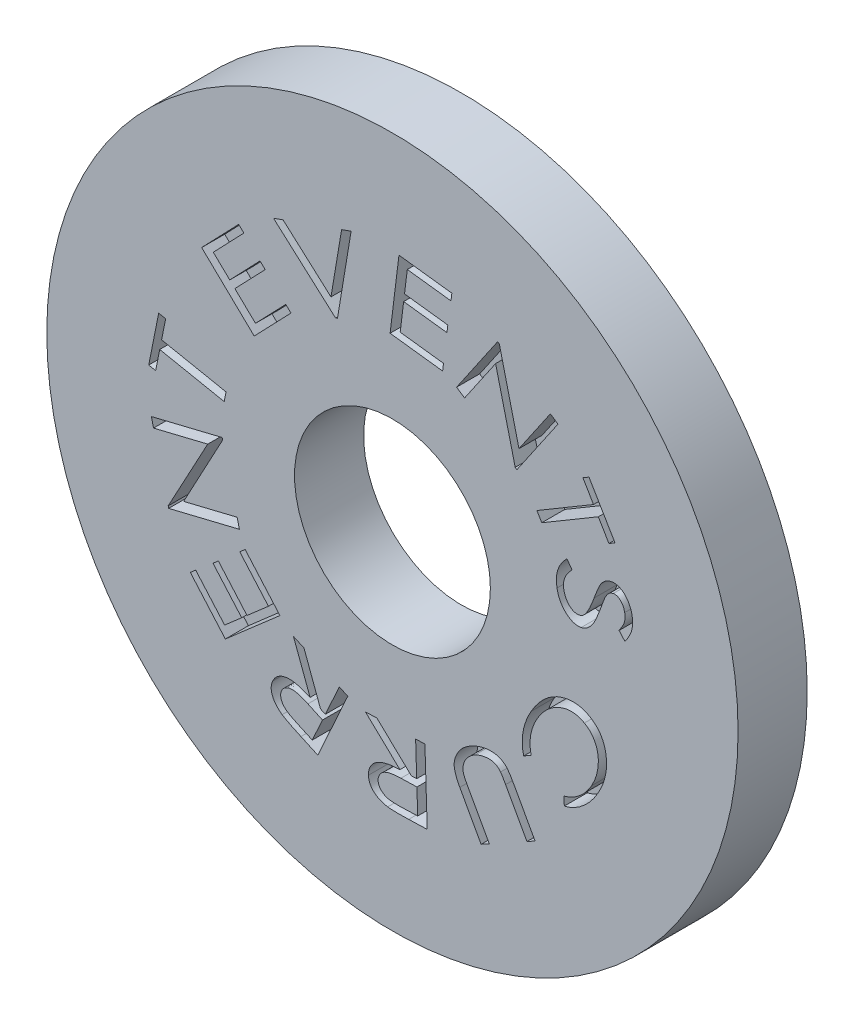
from build123d import *

# Parameters (mm, degrees)
SKETCH1_R           = 15
BOSS_EXTRUDE1_DEPTH = 3
SKETCH3_R           = 4.25
CUT_EXTRUDE1_DEPTH  = 4
CUT_EXTRUDE3_DEPTH  = 1


with BuildPart() as part:
    # Sketch1 → Boss-Extrude1 (new body)
    with BuildSketch(Plane.XY):
        Circle(SKETCH1_R)
    extrude(amount=BOSS_EXTRUDE1_DEPTH)

    # Sketch3 → Cut-Extrude1 (cut, through all)
    with BuildSketch(Plane.XY.offset(3)):
        Circle(SKETCH3_R)
    extrude(amount=-CUT_EXTRUDE1_DEPTH, mode=Mode.SUBTRACT)

    # Sketch7 → Cut-Extrude3 (cut)
    with BuildSketch(Plane.XY.offset(3)):
        with BuildLine():
            Line((7.572567921, 2.778173454), (7.793266038, 2.472884993))
            add(Edge.make_bspline(
                [(7.793266038, 2.472884993), (7.758243177, 2.435741938), (7.690623687, 2.364028938), (7.603508013, 2.250334888), (7.533286277, 2.135948941), (7.480151232, 2.020806722), (7.442138205, 1.905496622), (7.422287905, 1.789167337), (7.419200953, 1.672269445), (7.430271316, 1.595517723), (7.435824131, 1.557019608)],
                knots=[0, 0, 0, 0, 0.000153078, 0.000295552, 0.000428846, 0.000554914, 0.000675193, 0.000791989, 0.000907772, 0.001024295, 0.001024295, 0.001024295, 0.001024295], degree=3))
            add(Edge.make_bspline(
                [(7.435824131, 1.557019608), (7.442771562, 1.524610872), (7.456540718, 1.460379804), (7.4890804, 1.367902537), (7.529040709, 1.279839065), (7.576884374, 1.197526866), (7.63169335, 1.12390142), (7.690723663, 1.059825704), (7.755198845, 1.008566954), (7.822411558, 0.968045646), (7.892127768, 0.940052812), (7.961924082, 0.923007684), (8.031981335, 0.917975072), (8.077612177, 0.924229934), (8.100462552, 0.927362156)],
                knots=[0, 0, 0, 0, 9.9349e-05, 0.000196901, 0.000293385, 0.00038916, 0.000481892, 0.000568283, 0.000649733, 0.000728159, 0.00080292, 0.000874191, 0.000943025, 0.00101207, 0.00101207, 0.00101207, 0.00101207], degree=3))
            add(Edge.make_bspline(
                [(8.100462552, 0.927362156), (8.126084368, 0.933936214), (8.17844969, 0.947372132), (8.251872782, 0.988690006), (8.320684938, 1.046336853), (8.360264918, 1.093933283), (8.380946327, 1.118803462)],
                knots=[0, 0, 0, 0, 7.9074e-05, 0.000161609, 0.000250128, 0.000346997, 0.000346997, 0.000346997, 0.000346997], degree=3))
            add(Edge.make_bspline(
                [(8.380946327, 1.118803462), (8.39565008, 1.138962849), (8.426795504, 1.181664371), (8.470095641, 1.253575895), (8.515376991, 1.334878874), (8.560775252, 1.42654351), (8.607348756, 1.527873565), (8.654087191, 1.639448498), (8.702651197, 1.760788775), (8.733736506, 1.84568595), (8.749836551, 1.889656828)],
                knots=[0, 0, 0, 0, 7.4823e-05, 0.000158491, 0.000251586, 0.000353983, 0.000465259, 0.000586104, 0.000716847, 0.000857316, 0.000857316, 0.000857316, 0.000857316], degree=3))
            add(Edge.make_bspline(
                [(8.749836551, 1.889656828), (8.765811525, 1.933380955), (8.796297421, 2.01682204), (8.841979614, 2.135190747), (8.885448883, 2.240821815), (8.925013743, 2.334131591), (8.962128693, 2.414635037), (8.995504728, 2.482778827), (9.02603426, 2.538680429), (9.047896664, 2.570130158), (9.057669083, 2.584188078)],
                knots=[0, 0, 0, 0, 0.000139652, 0.000266505, 0.000380599, 0.000482318, 0.000570539, 0.000646484, 0.00070999, 0.000761323, 0.000761323, 0.000761323, 0.000761323], degree=3))
            add(Edge.make_bspline(
                [(9.057669083, 2.584188078), (9.072799978, 2.604399424), (9.102238214, 2.643722041), (9.151301418, 2.696828372), (9.201768533, 2.744088522), (9.255245124, 2.784479147), (9.310635476, 2.819101675), (9.368720334, 2.84737176), (9.429502978, 2.868385265), (9.471191145, 2.877776895), (9.492069123, 2.882480345)],
                knots=[0, 0, 0, 0, 7.5697e-05, 0.000147273, 0.000216585, 0.000282859, 0.000347985, 0.000412273, 0.000476236, 0.000540408, 0.000540408, 0.000540408, 0.000540408], degree=3))
            add(Edge.make_bspline(
                [(9.492069123, 2.882480345), (9.525487591, 2.887480101), (9.591522657, 2.897359645), (9.691872493, 2.891386261), (9.790280553, 2.869652966), (9.885796731, 2.830726385), (9.977833579, 2.777774496), (10.064054371, 2.709986522), (10.142852329, 2.626974709), (10.214626778, 2.531523883), (10.277647402, 2.425473252), (10.330077135, 2.311166633), (10.371940156, 2.189956218), (10.390336334, 2.105491425), (10.399666278, 2.062653623)],
                knots=[0, 0, 0, 0, 0.000101141, 0.000199855, 0.000299539, 0.000402291, 0.000508002, 0.000617169, 0.000730075, 0.00085041, 0.000974757, 0.001099404, 0.001227123, 0.001358557, 0.001358557, 0.001358557, 0.001358557], degree=3))
            add(Edge.make_bspline(
                [(10.399666278, 2.062653623), (10.406968125, 2.016545914), (10.421409034, 1.925358391), (10.426457156, 1.787710684), (10.415815967, 1.652205938), (10.396123285, 1.540457631), (10.371326108, 1.451471841), (10.3480234, 1.382372), (10.317425083, 1.312204002), (10.283312702, 1.238982201), (10.242466813, 1.164523065), (10.19630228, 1.087807297), (10.145158452, 1.009012467), (10.107344602, 0.957083536), (10.088017641, 0.930542244)],
                knots=[0, 0, 0, 0, 0.000139959, 0.000276797, 0.000412016, 0.000547123, 0.000616405, 0.000689014, 0.00076568, 0.000845909, 0.000931287, 0.001020294, 0.001114495, 0.001212977, 0.001212977, 0.001212977, 0.001212977], degree=3))
            Line((10.088017641, 0.930542244), (9.835518642, 1.21611416))
            add(Edge.make_bspline(
                [(9.835518642, 1.21611416), (9.850666738, 1.237884108), (9.879987813, 1.280022627), (9.920896489, 1.342137684), (9.956297727, 1.401704472), (9.988677296, 1.45737921), (10.015174277, 1.510900621), (10.037632888, 1.561125257), (10.055616413, 1.608227845), (10.073535384, 1.666851191), (10.087692838, 1.739748458), (10.095416924, 1.828210864), (10.093172952, 1.918782094), (10.08342497, 1.978777462), (10.078477376, 2.009228142)],
                knots=[0, 0, 0, 0, 7.9566e-05, 0.00015401, 0.000223055, 0.000287428, 0.00034716, 0.000402115, 0.000452437, 0.00049831, 0.000585873, 0.000674608, 0.000764322, 0.000856788, 0.000856788, 0.000856788, 0.000856788], degree=3))
            add(Edge.make_bspline(
                [(10.078477376, 2.009228142), (10.070009004, 2.047054558), (10.05372202, 2.11980505), (10.012851345, 2.220461733), (9.95867451, 2.306810013), (9.904349115, 2.36830856), (9.855554319, 2.40776404), (9.819470182, 2.434039548), (9.781592753, 2.453695577), (9.742935279, 2.468427785), (9.703756584, 2.478999274), (9.663496358, 2.48299816), (9.622638128, 2.483669132), (9.595490886, 2.47904305), (9.581747609, 2.476701099)],
                knots=[0, 0, 0, 0, 0.000116156, 0.0002234, 0.000323988, 0.000420807, 0.000467795, 0.000512083, 0.000554473, 0.000595342, 0.000636067, 0.00067575, 0.000716455, 0.000758191, 0.000758191, 0.000758191, 0.000758191], degree=3))
            add(Edge.make_bspline(
                [(9.581747609, 2.476701099), (9.565072377, 2.47292768), (9.53186137, 2.465412399), (9.483996766, 2.445591538), (9.438315171, 2.419487886), (9.393899829, 2.386365896), (9.351219073, 2.343576112), (9.308479524, 2.290504101), (9.267096025, 2.225041266), (9.24077765, 2.177078396), (9.226849772, 2.151696091)],
                knots=[0, 0, 0, 0, 5.1214e-05, 0.000102, 0.000154698, 0.000208759, 0.000267676, 0.000335518, 0.000412789, 0.000499646, 0.000499646, 0.000499646, 0.000499646], degree=3))
            add(Edge.make_bspline(
                [(9.226849772, 2.151696091), (9.222304384, 2.142196966), (9.211520681, 2.119660775), (9.195330118, 2.078817495), (9.174236103, 2.026370818), (9.149622593, 1.961414805), (9.120814592, 1.884312109), (9.08891472, 1.794783878), (9.051377586, 1.69361897), (9.026367472, 1.621730509), (9.013147849, 1.583732349)],
                knots=[0, 0, 0, 0, 3.1584e-05, 7.4931e-05, 0.00013174, 0.000201194, 0.000283302, 0.000378667, 0.000486312, 0.000607004, 0.000607004, 0.000607004, 0.000607004], degree=3))
            add(Edge.make_bspline(
                [(9.013147849, 1.583732349), (8.99693264, 1.537819533), (8.965599781, 1.449101604), (8.915081722, 1.322733423), (8.865446754, 1.206737233), (8.816841092, 1.100698278), (8.767229789, 1.005267137), (8.717832275, 0.920121637), (8.669136796, 0.845158972), (8.619566465, 0.780705237), (8.569276918, 0.724678569), (8.518337233, 0.6751533), (8.466904572, 0.630514961), (8.413224126, 0.593300395), (8.358839302, 0.560863449), (8.303010082, 0.534913767), (8.245924331, 0.514706891), (8.206996406, 0.506137069), (8.187596968, 0.501866363)],
                knots=[0, 0, 0, 0, 0.000146063, 0.000282239, 0.000408177, 0.000524561, 0.000632091, 0.000730705, 0.000819788, 0.00090006, 0.000974376, 0.001045439, 0.001113115, 0.001178402, 0.001241123, 0.001302869, 0.00136281, 0.001422355, 0.001422355, 0.001422355, 0.001422355], degree=3))
            add(Edge.make_bspline(
                [(8.187596968, 0.501866363), (8.15968128, 0.49741788), (8.104497268, 0.488624072), (8.020600014, 0.49028), (7.937808787, 0.50050963), (7.856040827, 0.523114416), (7.774748109, 0.55460006), (7.695152612, 0.598866223), (7.615816175, 0.652521274), (7.538602844, 0.716463895), (7.464506472, 0.787964483), (7.397782196, 0.867585622), (7.337029209, 0.952218288), (7.28351866, 1.042939592), (7.236984005, 1.139329352), (7.197507725, 1.241642056), (7.164835804, 1.349861065), (7.149262538, 1.424802589), (7.141347969, 1.462888999)],
                knots=[0, 0, 0, 0, 8.4648e-05, 0.000167332, 0.000250719, 0.000334337, 0.000421146, 0.000511651, 0.000606909, 0.000708134, 0.000812031, 0.000915374, 0.001019327, 0.00112426, 0.001230933, 0.001340069, 0.001452953, 0.001569608, 0.001569608, 0.001569608, 0.001569608], degree=3))
            add(Edge.make_bspline(
                [(7.141347969, 1.462888999), (7.136412961, 1.492528006), (7.126609492, 1.551406347), (7.116823072, 1.639489922), (7.113449983, 1.72658096), (7.113435033, 1.812193112), (7.120454573, 1.896647888), (7.130617689, 1.980058926), (7.147775334, 2.06206888), (7.168297821, 2.143515958), (7.196069086, 2.223982449), (7.229804578, 2.304094831), (7.269936956, 2.384274193), (7.318219776, 2.463251223), (7.371298936, 2.543242757), (7.432336273, 2.621889806), (7.498983797, 2.701221181), (7.547682473, 2.75214893), (7.572567921, 2.778173454)],
                knots=[0, 0, 0, 0, 9.0135e-05, 0.000179055, 0.000265637, 0.000351502, 0.000435697, 0.000519714, 0.00060341, 0.000686867, 0.000771543, 0.000858482, 0.000947511, 0.001040226, 0.001136011, 0.001235363, 0.001338705, 0.001446701, 0.001446701, 0.001446701, 0.001446701], degree=3))
        make_face()
        Polygon((8.266054911, 6.171653301), (8.530002227, 6.32747762), (9.658297499, 4.418788718), (9.394350183, 4.262964399), (8.935781473, 5.038905905), (6.480753428, 3.58687766), (6.270867611, 3.941775496), (8.725895656, 5.393803742), align=None)
        Polygon((2.785093321, 6.834011202), (4.566578698, 9.435959319), (4.639084708, 9.386349944), (5.491348329, 5.877440689), (6.854970124, 7.868811883), (7.183791238, 7.643661643), (5.402305861, 5.041713526), (5.327255781, 5.092594936), (4.476900212, 8.565251186), (3.129814876, 6.598048662), align=None)
        Polygon((0.282816593, 10.544771408), (2.578204213, 10.263015599), (2.540043155, 9.954547049), (0.644710623, 10.187329501), (0.525139309, 9.209134389), (2.403935383, 8.97825999), (2.365774325, 8.671699493), (0.486978251, 8.902573892), (0.336878091, 7.675695888), (2.215674165, 7.444821488), (2.177513107, 7.136352939), (-0.101338055, 7.416200695), align=None)
        Polygon((-5.160182932, 9.208626909), (-4.746771474, 9.355546982), (-2.667629847, 7.499011525), (-2.206517067, 10.259964049), (-1.793105608, 10.407520139), (-2.38523802, 6.836281156), (-2.467920312, 6.807024345), align=None)
        Polygon((-8.278789316, 6.549158581), (-6.672208787, 8.224429014), (-6.447058546, 8.008819038), (-7.773791319, 6.625480697), (-7.060815558, 5.941761746), (-5.745531103, 7.313015753), (-5.522288915, 7.098677812), (-6.83757337, 5.727423806), (-5.942696567, 4.869436025), (-4.627412112, 6.240690032), (-4.402897889, 6.025716073), (-5.998030101, 4.362529975), align=None)
        Polygon((-10.274879437, 0.92545457), (-10.576351793, 0.985240227), (-10.143859806, 3.150880251), (-9.84238745, 3.091094594), (-10.017928315, 2.210846197), (-7.220086769, 1.651786701), (-7.300861008, 1.249187543), (-10.098702554, 1.808247038), align=None)
        Polygon((-6.640662188, -3.220738253), (-9.710719279, -3.968694983), (-9.731071843, -3.883468621), (-8.016368318, -0.706560568), (-10.366453454, -1.278976434), (-10.460584063, -0.892913733), (-7.390526971, -0.144957003), (-7.368902372, -0.232727435), (-9.060073245, -3.381650712), (-6.73924492, -2.816231041), align=None)
        Polygon((-7.250871739, -7.6486715), (-8.770953871, -5.905983198), (-8.537535401, -5.702457557), (-7.282672621, -7.141129432), (-6.542348102, -6.49557154), (-7.786398582, -5.069620017), (-7.554888166, -4.867366411), (-6.310837685, -6.293317934), (-5.38161593, -5.483031476), (-6.625666411, -4.057079953), (-6.392247941, -3.853554312), (-4.88297811, -5.583522261), align=None)
        with BuildLine():
            Line((-3.237172262, -10.007422843), (-3.971136605, -9.674149605))
            add(Edge.make_bspline(
                [(-3.971136605, -9.674149605), (-4.020146303, -9.651756109), (-4.114099173, -9.608827192), (-4.248184689, -9.546048156), (-4.36920391, -9.487437973), (-4.477404668, -9.433501841), (-4.572817622, -9.383884078), (-4.655702968, -9.339192121), (-4.725065818, -9.29785805), (-4.766439641, -9.271023318), (-4.785239169, -9.258830094)],
                knots=[0, 0, 0, 0, 0.00016165, 0.000309887, 0.000444152, 0.000565037, 0.000672567, 0.000766777, 0.000847494, 0.000914713, 0.000914713, 0.000914713, 0.000914713], degree=3))
            add(Edge.make_bspline(
                [(-4.785239169, -9.258830094), (-4.809619315, -9.241301048), (-4.857476529, -9.206892259), (-4.924499844, -9.151341698), (-4.985759161, -9.093401721), (-5.041340121, -9.032899487), (-5.091024307, -8.969569706), (-5.135718183, -8.904396585), (-5.174014995, -8.836428788), (-5.206610336, -8.766842665), (-5.231839513, -8.695637943), (-5.250778671, -8.624481215), (-5.260979519, -8.553176931), (-5.263308176, -8.482219), (-5.259273124, -8.411137756), (-5.246012609, -8.340247027), (-5.225999546, -8.26932921), (-5.206576606, -8.223633142), (-5.196742574, -8.200496761)],
                knots=[0, 0, 0, 0, 9.0063e-05, 0.000176791, 0.000260921, 0.000342851, 0.000423012, 0.000502218, 0.000579687, 0.000656803, 0.000732444, 0.000806027, 0.000877354, 0.000947998, 0.001018736, 0.001090471, 0.001163944, 0.001239296, 0.001239296, 0.001239296, 0.001239296], degree=3))
            add(Edge.make_bspline(
                [(-5.196742574, -8.200496761), (-5.187486087, -8.181478543), (-5.16923604, -8.143982313), (-5.137237263, -8.090920657), (-5.101552439, -8.041711157), (-5.061993645, -7.996542661), (-5.01898891, -7.954907952), (-4.972766314, -7.916518493), (-4.922170125, -7.882979442), (-4.868593029, -7.853000283), (-4.811921368, -7.826759221), (-4.752247377, -7.805389603), (-4.690198955, -7.788079247), (-4.625562416, -7.775271329), (-4.558354949, -7.767435134), (-4.488507454, -7.762515184), (-4.416263048, -7.763595048), (-4.341055421, -7.768540713), (-4.262133849, -7.779236592), (-4.178310125, -7.794069234), (-4.089853576, -7.816451239), (-3.996189527, -7.842997447), (-3.89758418, -7.875633483), (-3.794217172, -7.913961151), (-3.685420602, -7.95716586), (-3.612100137, -7.989714164), (-3.574261605, -8.006511384)],
                knots=[0, 0, 0, 0, 6.343e-05, 0.000125058, 0.000185613, 0.000245565, 0.000304936, 0.000365035, 0.000425541, 0.000486761, 0.000549084, 0.00061266, 0.000676699, 0.000742184, 0.000810107, 0.000879576, 0.000952085, 0.001026673, 0.001105562, 0.001190893, 0.001281905, 0.001379141, 0.001482923, 0.001593395, 0.001709847, 0.001834033, 0.001834033, 0.001834033, 0.001834033], degree=3))
            Line((-3.574261605, -8.006511384), (-4.294869577, -6.073017795))
            Line((-4.294869577, -6.073017795), (-3.838844938, -6.279723524))
            Line((-3.838844938, -6.279723524), (-3.120781036, -8.211945078))
            Line((-3.120781036, -8.211945078), (-2.910259201, -8.307347722))
            Line((-2.910259201, -8.307347722), (-2.306042454, -6.974890791))
            Line((-2.306042454, -6.974890791), (-1.937788247, -7.142163428))
            Line((-1.937788247, -7.142163428), (-3.237172262, -10.007422843))
        make_face()
        with BuildLine():
            Line((-3.478222943, -9.559666432), (-3.036826709, -8.585923444))
            Line((-3.036826709, -8.585923444), (-3.668392214, -8.29462737))
            add(Edge.make_bspline(
                [(-3.668392214, -8.29462737), (-3.698236127, -8.281371688), (-3.755786989, -8.255809492), (-3.839890685, -8.2206021), (-3.918923424, -8.190237326), (-3.992430387, -8.163084189), (-4.061262269, -8.14143662), (-4.124990725, -8.124393506), (-4.183168223, -8.110437329), (-4.252752908, -8.099953278), (-4.333631815, -8.093080903), (-4.42610868, -8.099771178), (-4.512959553, -8.117727357), (-4.592613945, -8.149241155), (-4.664333348, -8.190833051), (-4.725383988, -8.243356856), (-4.777222122, -8.303992993), (-4.801179872, -8.351089281), (-4.813223944, -8.374765591)],
                knots=[0, 0, 0, 0, 9.7965e-05, 0.000188916, 0.000273485, 0.00035195, 0.000423963, 0.000489842, 0.000549861, 0.000603294, 0.000700856, 0.000792663, 0.000880484, 0.000965876, 0.001048559, 0.001127962, 0.001206545, 0.001285989, 0.001285989, 0.001285989, 0.001285989], degree=3))
            add(Edge.make_bspline(
                [(-4.813223944, -8.374765591), (-4.822696139, -8.398864772), (-4.84153128, -8.446785183), (-4.852162702, -8.523882148), (-4.850569538, -8.603069594), (-4.833330968, -8.683269469), (-4.80429523, -8.762326425), (-4.763225082, -8.837826274), (-4.709305298, -8.907176674), (-4.65634421, -8.962074624), (-4.605150991, -9.003570219), (-4.558846766, -9.036876631), (-4.504997641, -9.071439066), (-4.443861007, -9.107637425), (-4.375316107, -9.145325843), (-4.299329892, -9.184427478), (-4.215860386, -9.225315956), (-4.157346384, -9.251980028), (-4.126960924, -9.265826288)],
                knots=[0, 0, 0, 0, 7.744e-05, 0.000153987, 0.000231605, 0.000314054, 0.000398769, 0.000483589, 0.000570725, 0.000661576, 0.000711741, 0.000768228, 0.00083262, 0.000903629, 0.000981343, 0.00106725, 0.00115998, 0.001260151, 0.001260151, 0.001260151, 0.001260151], degree=3))
            Line((-4.126960924, -9.265826288), (-3.478222943, -9.559666432))
        make_face(mode=Mode.SUBTRACT)
        with BuildLine():
            Line((1.509342292, -10.423242667), (0.70541601, -10.448683372))
            add(Edge.make_bspline(
                [(0.70541601, -10.448683372), (0.651569566, -10.450311331), (0.548551903, -10.4534259), (0.400770495, -10.455626111), (0.266563096, -10.457556859), (0.145711011, -10.455859051), (0.038400825, -10.453762096), (-0.055331815, -10.449303709), (-0.1355883, -10.443512412), (-0.184394549, -10.437015366), (-0.206633269, -10.434054967)],
                knots=[0, 0, 0, 0, 0.00016161, 0.000309188, 0.000443394, 0.000564244, 0.000671761, 0.000765361, 0.000845751, 0.000913043, 0.000913043, 0.000913043, 0.000913043], degree=3))
            add(Edge.make_bspline(
                [(-0.206633269, -10.434054967), (-0.236176413, -10.429362298), (-0.294370217, -10.420118724), (-0.378974702, -10.399683644), (-0.459387552, -10.374042103), (-0.535788646, -10.344350645), (-0.607994632, -10.309772914), (-0.676415142, -10.270961648), (-0.740838163, -10.227133229), (-0.800310677, -10.178058503), (-0.85510092, -10.125990255), (-0.902606148, -10.069278931), (-0.943254704, -10.009598552), (-0.977550372, -9.946684757), (-1.004085241, -9.880426318), (-1.024026314, -9.810993089), (-1.036953546, -9.738280026), (-1.039696118, -9.688481857), (-1.041088397, -9.663201602)],
                knots=[0, 0, 0, 0, 8.9715e-05, 0.000176719, 0.000260798, 0.000342766, 0.00042242, 0.000500757, 0.000578554, 0.000655837, 0.000731854, 0.000804982, 0.000877309, 0.00094817, 0.001019506, 0.00109097, 0.001164583, 0.001240486, 0.001240486, 0.001240486, 0.001240486], degree=3))
            add(Edge.make_bspline(
                [(-1.041088397, -9.663201602), (-1.041189125, -9.64199241), (-1.041387886, -9.600141485), (-1.036264453, -9.538217252), (-1.026194798, -9.478165407), (-1.010538434, -9.420029325), (-0.991253251, -9.363385671), (-0.965915042, -9.308863849), (-0.936125659, -9.255976903), (-0.900892029, -9.205154842), (-0.861670186, -9.156395494), (-0.818260481, -9.110007089), (-0.769566923, -9.067738353), (-0.717329048, -9.027579966), (-0.661252004, -8.989808753), (-0.60061508, -8.955464215), (-0.535432832, -8.924403871), (-0.465801986, -8.895734199), (-0.390630954, -8.86916278), (-0.308738709, -8.846617528), (-0.219662444, -8.827250893), (-0.124152951, -8.808985211), (-0.021262709, -8.795800359), (0.088074005, -8.783290844), (0.204550294, -8.774487681), (0.284572029, -8.771257541), (0.325713486, -8.769596834)],
                knots=[0, 0, 0, 0, 6.3605e-05, 0.000125508, 0.000186154, 0.00024601, 0.000305951, 0.000365432, 0.000426097, 0.000487843, 0.000550719, 0.000613707, 0.000678146, 0.000743915, 0.0008113, 0.000880801, 0.000952772, 0.001027773, 0.001106624, 0.001191806, 0.001282384, 0.00138006, 0.00148341, 0.001593471, 0.001710202, 0.001833722, 0.001833722, 0.001833722, 0.001833722], degree=3))
            Line((0.325713486, -8.769596834), (-1.172108029, -7.3468254))
            Line((-1.172108029, -7.3468254), (-0.67283419, -7.331560977))
            Line((-0.67283419, -7.331560977), (0.821807236, -8.754332411))
            Line((0.821807236, -8.754332411), (1.052681635, -8.746700199))
            Line((1.052681635, -8.746700199), (1.006252348, -7.278135496))
            Line((1.006252348, -7.278135496), (1.409487524, -7.265415143))
            Line((1.409487524, -7.265415143), (1.509342292, -10.423242667))
        make_face()
        with BuildLine():
            Line((1.095930834, -10.126858452), (1.062221899, -9.053260696))
            Line((1.062221899, -9.053260696), (0.368326667, -9.07106919))
            add(Edge.make_bspline(
                [(0.368326667, -9.07106919), (0.33588316, -9.072185652), (0.273079977, -9.074346868), (0.182089201, -9.080018628), (0.09772012, -9.087781539), (0.020011804, -9.096275187), (-0.050974472, -9.107403461), (-0.115601375, -9.119028759), (-0.173638958, -9.132850454), (-0.240695018, -9.15384049), (-0.315647858, -9.184860175), (-0.396539891, -9.230313402), (-0.465208704, -9.286725536), (-0.523253141, -9.349890253), (-0.568766809, -9.419578765), (-0.601121248, -9.49342149), (-0.619753855, -9.571105149), (-0.620793043, -9.623882862), (-0.621316763, -9.650481249)],
                knots=[0, 0, 0, 0, 9.7385e-05, 0.000188516, 0.00027345, 0.000351553, 0.000422974, 0.000488964, 0.000548509, 0.000601817, 0.000699617, 0.000791365, 0.000879075, 0.000965069, 0.001047805, 0.001127562, 0.001205934, 0.001285561, 0.001285561, 0.001285561, 0.001285561], degree=3))
            add(Edge.make_bspline(
                [(-0.621316763, -9.650481249), (-0.619132788, -9.676523058), (-0.614807756, -9.72809491), (-0.590655561, -9.802590273), (-0.553901055, -9.873074848), (-0.503388146, -9.937874595), (-0.442818901, -9.996368254), (-0.37235469, -10.044810117), (-0.294516379, -10.084833355), (-0.222540404, -10.109813228), (-0.15818961, -10.124634772), (-0.102104108, -10.133998584), (-0.038856168, -10.141535882), (0.031798571, -10.14713556), (0.109854548, -10.150779177), (0.195320632, -10.152847786), (0.287986196, -10.151770867), (0.35221587, -10.150443116), (0.385499143, -10.149755087)],
                knots=[0, 0, 0, 0, 7.8178e-05, 0.000154821, 0.000233053, 0.000315613, 0.000400182, 0.000484696, 0.000571168, 0.000662086, 0.000712379, 0.000769156, 0.000832583, 0.000903412, 0.000981736, 0.001066983, 0.001159844, 0.001259717, 0.001259717, 0.001259717, 0.001259717], degree=3))
            Line((0.385499143, -10.149755087), (1.095930834, -10.126858452))
        make_face(mode=Mode.SUBTRACT)
        with BuildLine():
            Line((6.191057377, -8.520544266), (5.837431576, -8.715801678))
            Line((5.837431576, -8.715801678), (4.912025927, -7.03925921))
            add(Edge.make_bspline(
                [(4.912025927, -7.03925921), (4.898954653, -7.015473584), (4.87413044, -6.97030129), (4.837799187, -6.906859676), (4.805172575, -6.850451096), (4.776144425, -6.801255107), (4.750870923, -6.759033434), (4.728509639, -6.724517425), (4.709591469, -6.697175004), (4.697732068, -6.681572975), (4.692599845, -6.674821109)],
                knots=[0, 0, 0, 0, 8.142e-05, 0.000154629, 0.000219318, 0.000276912, 0.000325997, 0.000366925, 0.000400272, 0.000425713, 0.000425713, 0.000425713, 0.000425713], degree=3))
            add(Edge.make_bspline(
                [(4.692599845, -6.674821109), (4.672820686, -6.651386751), (4.634125707, -6.605540922), (4.567520787, -6.547183933), (4.495447406, -6.500815905), (4.417582572, -6.465540476), (4.331729499, -6.442554433), (4.236480582, -6.431425365), (4.131082711, -6.432867156), (4.018174988, -6.44526105), (3.902207463, -6.466661434), (3.789010558, -6.499587813), (3.679837465, -6.540421288), (3.611268798, -6.575761566), (3.577024925, -6.593410853)],
                knots=[0, 0, 0, 0, 9.1904e-05, 0.000179796, 0.00026448, 0.000348174, 0.000435194, 0.000530019, 0.000634963, 0.000750715, 0.000870466, 0.000988232, 0.001103989, 0.001219473, 0.001219473, 0.001219473, 0.001219473], degree=3))
            add(Edge.make_bspline(
                [(3.577024925, -6.593410853), (3.548469496, -6.610031872), (3.491601064, -6.643132805), (3.413039883, -6.702369578), (3.339358313, -6.766670561), (3.272432261, -6.836659046), (3.213585244, -6.91095606), (3.16251349, -6.987239819), (3.122471042, -7.066640051), (3.09144187, -7.147728239), (3.070989552, -7.230850528), (3.060890525, -7.315381511), (3.060288665, -7.401570841), (3.068919362, -7.458674622), (3.073298964, -7.487651638)],
                knots=[0, 0, 0, 0, 9.9043e-05, 0.000197246, 0.000294592, 0.00039221, 0.000487268, 0.000578645, 0.000667106, 0.000753457, 0.000838607, 0.000923176, 0.001008403, 0.001096205, 0.001096205, 0.001096205, 0.001096205], degree=3))
            add(Edge.make_bspline(
                [(3.073298964, -7.487651638), (3.07559395, -7.499167103), (3.080683432, -7.524704414), (3.095167511, -7.56526991), (3.112440662, -7.612842317), (3.135847138, -7.666335178), (3.163789239, -7.726162405), (3.197329789, -7.792195528), (3.23424853, -7.865465217), (3.262213471, -7.915582781), (3.276824605, -7.941768224)],
                knots=[0, 0, 0, 0, 3.5183e-05, 7.8023e-05, 0.00012894, 0.000187066, 0.000253077, 0.00032703, 0.000409236, 0.000499183, 0.000499183, 0.000499183, 0.000499183], degree=3))
            Line((3.276824605, -7.941768224), (4.202230254, -9.618310692))
            Line((4.202230254, -9.618310692), (3.848604453, -9.813568104))
            Line((3.848604453, -9.813568104), (2.923198803, -8.137025636))
            add(Edge.make_bspline(
                [(2.923198803, -8.137025636), (2.906654817, -8.106612858), (2.874433331, -8.047380164), (2.830940845, -7.958775336), (2.793606588, -7.872573846), (2.760235647, -7.789675837), (2.732775714, -7.70944742), (2.710997202, -7.63213139), (2.694498141, -7.557804789), (2.682383678, -7.485705962), (2.677052643, -7.413944142), (2.679355442, -7.341588122), (2.687268473, -7.267601066), (2.70402559, -7.192814743), (2.72509719, -7.115922813), (2.755076311, -7.038489636), (2.790593824, -6.959306729), (2.833243347, -6.879737723), (2.88137263, -6.800331792), (2.937964123, -6.724660753), (3.000389221, -6.651722174), (3.069995811, -6.582519366), (3.145871287, -6.516276234), (3.227996867, -6.453286636), (3.31677829, -6.393742866), (3.379623682, -6.357907561), (3.411660342, -6.339639819)],
                knots=[0, 0, 0, 0, 0.000103858, 0.000202276, 0.000295981, 0.000385623, 0.000470299, 0.000550238, 0.000626467, 0.000698615, 0.000769396, 0.000841928, 0.000915535, 0.000992251, 0.001071578, 0.001154504, 0.00124104, 0.001331804, 0.001425179, 0.001519312, 0.001614926, 0.001712968, 0.001813485, 0.001916908, 0.002023277, 0.002133886, 0.002133886, 0.002133886, 0.002133886], degree=3))
            add(Edge.make_bspline(
                [(3.411660342, -6.339639819), (3.446906689, -6.320889326), (3.516404739, -6.283917476), (3.621582344, -6.234676746), (3.726630967, -6.194217713), (3.8299655, -6.159295841), (3.932789392, -6.133051829), (4.033854438, -6.111786068), (4.134347032, -6.100295966), (4.232879177, -6.094239904), (4.328986891, -6.09539918), (4.421018584, -6.103696189), (4.508777376, -6.118008293), (4.591672404, -6.139898795), (4.67031381, -6.167510609), (4.744021925, -6.203114171), (4.813628635, -6.244602132), (4.855963131, -6.277900548), (4.877044957, -6.294482567)],
                knots=[0, 0, 0, 0, 0.000119764, 0.000236148, 0.000348116, 0.000457328, 0.000563154, 0.000666308, 0.000766892, 0.000866275, 0.000962323, 0.001054915, 0.001143269, 0.001228732, 0.001311817, 0.001392894, 0.001473938, 0.001554331, 0.001554331, 0.001554331, 0.001554331], degree=3))
            add(Edge.make_bspline(
                [(4.877044957, -6.294482567), (4.890621193, -6.306337136), (4.919913774, -6.331914983), (4.961997716, -6.378115401), (5.006358918, -6.433366166), (5.054508765, -6.496857515), (5.103437776, -6.570914033), (5.155619246, -6.65360276), (5.210462731, -6.745359261), (5.246738541, -6.810197148), (5.265651728, -6.844001798)],
                knots=[0, 0, 0, 0, 5.4035e-05, 0.000116589, 0.000187115, 0.000266617, 0.000355523, 0.00045328, 0.000559956, 0.00067616, 0.00067616, 0.00067616, 0.00067616], degree=3))
            Line((5.265651728, -6.844001798), (6.191057377, -8.520544266))
        make_face()
        with BuildLine():
            Line((7.45737364, -6.573379332), (7.449105411, -6.201945037))
            add(Edge.make_bspline(
                [(7.449105411, -6.201945037), (7.47930296, -6.193344988), (7.53955588, -6.176185379), (7.628035559, -6.145080082), (7.714159568, -6.108313695), (7.798917616, -6.067883745), (7.881654446, -6.021870158), (7.962529124, -5.971174136), (8.040762286, -5.914603411), (8.11772877, -5.854563347), (8.192166724, -5.789509858), (8.264135267, -5.720111425), (8.333335699, -5.646271051), (8.400099857, -5.568552792), (8.464722719, -5.48723982), (8.525315192, -5.400847952), (8.58511967, -5.31154628), (8.621410586, -5.24897568), (8.639730411, -5.217389749)],
                knots=[0, 0, 0, 0, 9.4182e-05, 0.000187921, 0.000281123, 0.000374998, 0.000469514, 0.000564978, 0.000661168, 0.000759012, 0.000857734, 0.000957591, 0.00105883, 0.001161205, 0.001264907, 0.001370265, 0.001477694, 0.001587207, 0.001587207, 0.001587207, 0.001587207], degree=3))
            add(Edge.make_bspline(
                [(8.639730411, -5.217389749), (8.658925525, -5.182367789), (8.69699163, -5.112915242), (8.747874704, -5.006621284), (8.79248841, -4.899354697), (8.831443884, -4.79140303), (8.863820921, -4.682185772), (8.890759241, -4.572299506), (8.910875063, -4.461386814), (8.925773479, -4.350403432), (8.933613874, -4.240600391), (8.936840666, -4.133160793), (8.93194727, -4.0288894), (8.922106221, -3.92752879), (8.905625974, -3.829310018), (8.882340624, -3.734274857), (8.854355444, -3.641863373), (8.818228275, -3.553520587), (8.777322824, -3.468848033), (8.729799539, -3.38920654), (8.677787957, -3.313802574), (8.619873401, -3.243614476), (8.555655248, -3.179094005), (8.486050059, -3.119263844), (8.411374903, -3.063557772), (8.357638453, -3.031574361), (8.330625843, -3.01549672)],
                knots=[0, 0, 0, 0, 0.000119796, 0.000237569, 0.000353325, 0.000468197, 0.000581691, 0.000694918, 0.000807441, 0.000919701, 0.001030677, 0.001137558, 0.00124196, 0.001343597, 0.00144293, 0.001540423, 0.001636985, 0.001732297, 0.001826449, 0.001918838, 0.00201023, 0.002101029, 0.002191426, 0.002282971, 0.002376214, 0.002470465, 0.002470465, 0.002470465, 0.002470465], degree=3))
            add(Edge.make_bspline(
                [(8.330625843, -3.01549672), (8.288723565, -2.993212598), (8.206395685, -2.949429668), (8.075525441, -2.903034249), (7.942532821, -2.872823471), (7.806630155, -2.859210508), (7.668036388, -2.863529259), (7.527016077, -2.884072734), (7.38350926, -2.921776257), (7.238878624, -2.974955945), (7.096323443, -3.043278436), (6.958399137, -3.125185674), (6.827492564, -3.221100383), (6.702174702, -3.329380439), (6.584604066, -3.451921555), (6.472020733, -3.586288946), (6.367121457, -3.735055578), (6.303600258, -3.841047217), (6.271200763, -3.8951091)],
                knots=[0, 0, 0, 0, 0.000142218, 0.000279424, 0.000415051, 0.000550546, 0.000687979, 0.000830005, 0.000977171, 0.001132309, 0.001291618, 0.001450761, 0.001612835, 0.001777851, 0.001946972, 0.002121729, 0.002303316, 0.002492359, 0.002492359, 0.002492359, 0.002492359], degree=3))
            add(Edge.make_bspline(
                [(6.271200763, -3.8951091), (6.238115931, -3.956059524), (6.173101652, -4.07583187), (6.095443252, -4.261763237), (6.036648644, -4.448331248), (5.995497141, -4.635172692), (5.972941622, -4.822850101), (5.969389074, -5.0109068), (5.983242737, -5.199843545), (6.007666808, -5.324006325), (6.0199738, -5.386570438)],
                knots=[0, 0, 0, 0, 0.000207951, 0.000408639, 0.000603356, 0.000794103, 0.000981781, 0.001169445, 0.00135764, 0.001548784, 0.001548784, 0.001548784, 0.001548784], degree=3))
            Line((6.0199738, -5.386570438), (5.697512862, -5.569107497))
            add(Edge.make_bspline(
                [(5.697512862, -5.569107497), (5.688837826, -5.534641828), (5.671380479, -5.465284296), (5.652550593, -5.359262188), (5.639918753, -5.251153001), (5.632756031, -5.141391584), (5.632392981, -5.029493179), (5.637473961, -4.915936996), (5.648299713, -4.800228034), (5.665454526, -4.682824842), (5.68913516, -4.564248604), (5.71819923, -4.445065585), (5.75424682, -4.325969663), (5.795502987, -4.206180638), (5.843151702, -4.086008453), (5.897693695, -3.965793136), (5.957001245, -3.844688052), (6.001367604, -3.765375927), (6.023789906, -3.725292393)],
                knots=[0, 0, 0, 0, 0.000106597, 0.000214512, 0.000322749, 0.000433002, 0.000544307, 0.000658268, 0.000773894, 0.000892804, 0.001014045, 0.001136526, 0.00126068, 0.001387196, 0.001516522, 0.001648326, 0.00178315, 0.001920912, 0.001920912, 0.001920912, 0.001920912], degree=3))
            add(Edge.make_bspline(
                [(6.023789906, -3.725292393), (6.045750749, -3.687584093), (6.089023529, -3.613281708), (6.158339518, -3.506312246), (6.228396485, -3.403866512), (6.301450849, -3.307072847), (6.375364011, -3.214565871), (6.452640457, -3.12815074), (6.531517195, -3.046624202), (6.612091503, -2.970100364), (6.695328817, -2.899559373), (6.779571805, -2.832890856), (6.866930081, -2.772923064), (6.955550033, -2.717015421), (7.04655898, -2.666932612), (7.13967261, -2.621553436), (7.234821481, -2.581450536), (7.299729201, -2.558717517), (7.332078167, -2.547387746)],
                knots=[0, 0, 0, 0, 0.000130893, 0.000257918, 0.000382295, 0.000503138, 0.000621639, 0.000737417, 0.000850764, 0.000961893, 0.001070614, 0.001177996, 0.00128403, 0.001388325, 0.001492232, 0.001595488, 0.001698964, 0.001801773, 0.001801773, 0.001801773, 0.001801773], degree=3))
            add(Edge.make_bspline(
                [(7.332078167, -2.547387746), (7.386509418, -2.531280099), (7.493211626, -2.499704095), (7.655226119, -2.47105525), (7.814415014, -2.459532853), (7.971044688, -2.464023749), (8.124763793, -2.487556477), (8.275750592, -2.52718848), (8.424324952, -2.583786103), (8.51873781, -2.633918576), (8.566588383, -2.659326848)],
                knots=[0, 0, 0, 0, 0.000170193, 0.000333631, 0.000492412, 0.00064832, 0.000802672, 0.000957865, 0.001115906, 0.00127832, 0.00127832, 0.00127832, 0.00127832], degree=3))
            add(Edge.make_bspline(
                [(8.566588383, -2.659326848), (8.591150899, -2.673878135), (8.640106628, -2.70288041), (8.709743708, -2.751173668), (8.775493984, -2.802888533), (8.837304405, -2.85767487), (8.895466299, -2.915702444), (8.949534414, -2.977254253), (8.999056803, -3.042692982), (9.04597124, -3.110535433), (9.08765453, -3.182706961), (9.125918601, -3.257844234), (9.160411892, -3.336381902), (9.190788461, -3.418412692), (9.217529858, -3.503754583), (9.240330915, -3.592293882), (9.259673439, -3.684124591), (9.278684226, -3.811236236), (9.29348601, -3.973159184), (9.29261805, -4.169668563), (9.274073072, -4.367180144), (9.237481633, -4.565903809), (9.182817226, -4.765440505), (9.111344197, -4.966488383), (9.021460836, -5.168540287), (8.949758072, -5.300329486), (8.913217991, -5.367489909)],
                knots=[0, 0, 0, 0, 8.5626e-05, 0.000170663, 0.000254003, 0.000336453, 0.000418304, 0.000500333, 0.000582001, 0.000664384, 0.000747615, 0.00083181, 0.000917247, 0.001004789, 0.001094104, 0.001185427, 0.00127898, 0.001375498, 0.001570876, 0.001766134, 0.00196416, 0.002165257, 0.00237154, 0.002584173, 0.002804835, 0.003034141, 0.003034141, 0.003034141, 0.003034141], degree=3))
            add(Edge.make_bspline(
                [(8.913217991, -5.367489909), (8.889605993, -5.407771191), (8.843063829, -5.487170576), (8.768035809, -5.601325553), (8.690918817, -5.710160263), (8.60963545, -5.812766615), (8.52587342, -5.910201407), (8.438662693, -6.001942903), (8.348263671, -6.087699554), (8.255593924, -6.168097734), (8.160253312, -6.241385194), (8.063995901, -6.309327846), (7.966488154, -6.37038757), (7.866989715, -6.423906264), (7.766862842, -6.471963823), (7.664872617, -6.512269472), (7.562181661, -6.547561974), (7.492291036, -6.564778131), (7.45737364, -6.573379332)],
                knots=[0, 0, 0, 0, 0.000140054, 0.000276064, 0.000409665, 0.000540088, 0.000668609, 0.000795023, 0.000919638, 0.001042296, 0.001162898, 0.001280238, 0.001395657, 0.001507785, 0.001619023, 0.001728625, 0.00183663, 0.001944463, 0.001944463, 0.001944463, 0.001944463], degree=3))
        make_face()
    extrude(amount=-CUT_EXTRUDE3_DEPTH, mode=Mode.SUBTRACT)


solid = part.part
